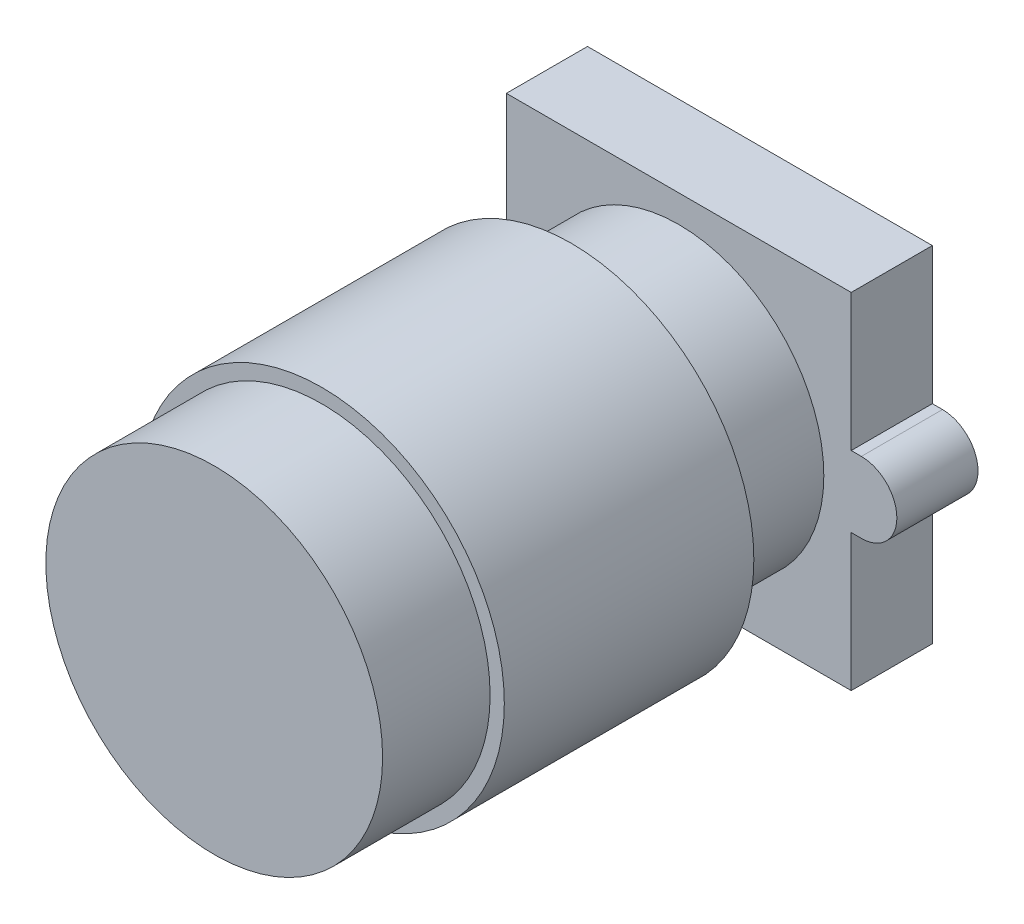
from build123d import *

# Parameters (mm, degrees)
SKETCH2_W           = 17
SKETCH2_H           = 3.5
SKETCH2_H_2         = 6.75
BOSS_EXTRUDE1_DEPTH = 4
SKETCH3_R           = 7.15
BOSS_EXTRUDE2_DEPTH = 5.3
SKETCH4_R           = 9
BOSS_EXTRUDE3_DEPTH = 12.3
SKETCH5_R           = 8.3
BOSS_EXTRUDE4_DEPTH = 5.3


with BuildPart() as part:
    # Sketch2 → Boss-Extrude1 (new body)
    with BuildSketch(Plane.XY):
        Rectangle(SKETCH2_W, SKETCH2_H)
        with BuildLine():
            Line((-9, -1.75), (-8.5, -1.75))
            Line((-8.5, -1.75), (-8.5, 1.75))
            Line((-8.5, 1.75), (-9, 1.75))
            ThreePointArc((-9, 1.75), (-10.75, 0), (-9, -1.75))
        make_face()
        with Locations((0, 5.125)):
            Rectangle(SKETCH2_W, SKETCH2_H_2)
        with Locations((0, -5.125)):
            Rectangle(SKETCH2_W, SKETCH2_H_2)
        with BuildLine():
            Line((8.5, 1.75), (8.5, -1.75))
            Line((8.5, -1.75), (9, -1.75))
            ThreePointArc((9, -1.75), (10.75, 0), (9, 1.75))
            Line((9, 1.75), (8.5, 1.75))
        make_face()
    extrude(amount=BOSS_EXTRUDE1_DEPTH)

    # Sketch3 → Boss-Extrude2 (add)
    with BuildSketch(Plane.XY.offset(4)):
        Circle(SKETCH3_R)
    extrude(amount=BOSS_EXTRUDE2_DEPTH)

    # Sketch4 → Boss-Extrude3 (add)
    with BuildSketch(Plane.XY.offset(9.3)):
        Circle(SKETCH4_R)
    extrude(amount=BOSS_EXTRUDE3_DEPTH)

    # Sketch5 → Boss-Extrude4 (add)
    with BuildSketch(Plane.XY.offset(21.6)):
        Circle(SKETCH5_R)
    extrude(amount=BOSS_EXTRUDE4_DEPTH)


solid = part.part
